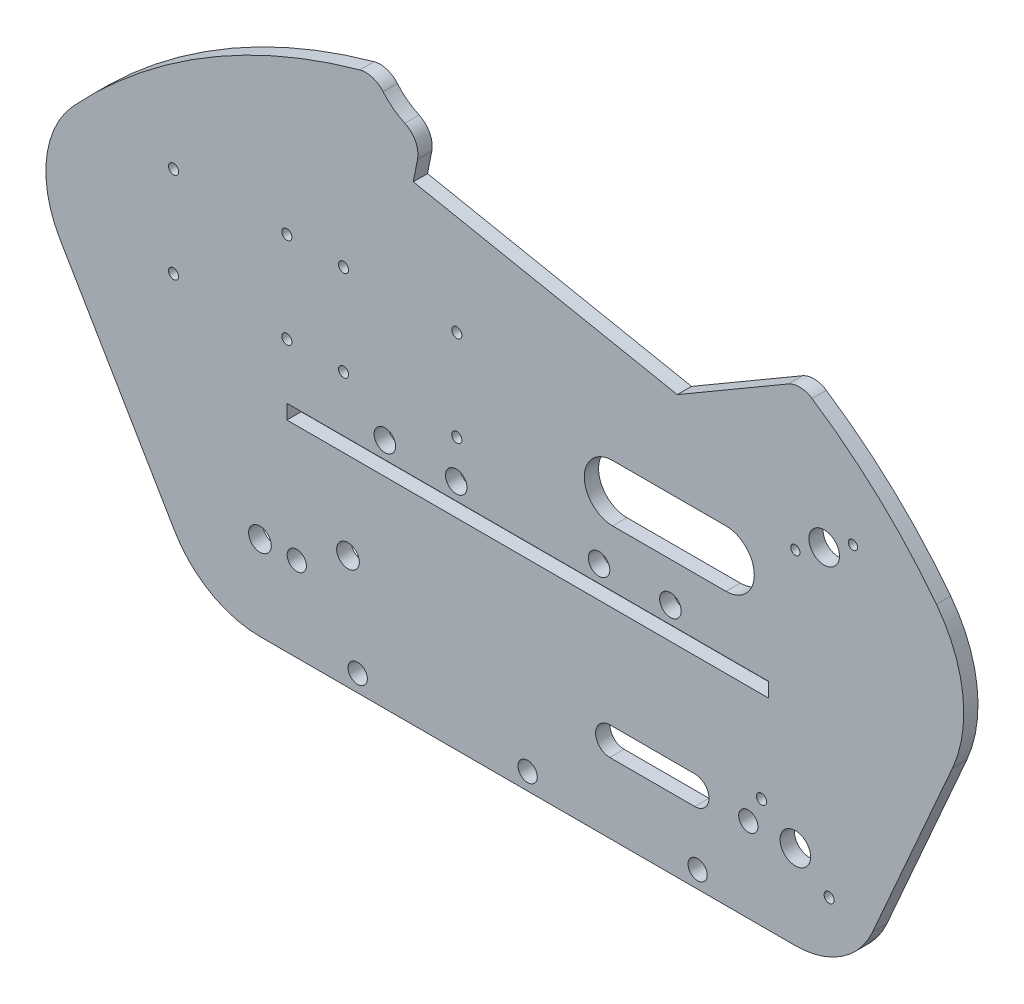
from build123d import *

# Parameters (mm, degrees)
SKETCH1_R           = 3.429
SKETCH1_R_2         = 2.54
BOSS_EXTRUDE1_DEPTH = 3.2004
SKETCH2_R           = 2.413
CUT_EXTRUDE1_DEPTH  = 3.2004
SKETCH3_R           = 2.159
CUT_EXTRUDE2_DEPTH  = 3.2004
SKETCH6_W           = 107.95
SKETCH6_H           = 3.2512
CUT_EXTRUDE3_DEPTH  = 3.2004
SKETCH7_R           = 3.429
CUT_EXTRUDE4_DEPTH  = 3.2004
CUT_EXTRUDE5_DEPTH  = 3.2004
CUT_EXTRUDE6_DEPTH  = 3.2004
BOSS_EXTRUDE2_DEPTH = 3.2004
SKETCH13_R          = 1.1303
CUT_EXTRUDE7_DEPTH  = 3.2004
CUT_EXTRUDE8_DEPTH  = 3.2004
FILLET1_R           = 5.08
SKETCH16_R          = 1.1303
SKETCH16_R_2        = 1.025
CUT_EXTRUDE9_DEPTH  = 3.2004
SKETCH20_R          = 2.159
CUT_EXTRUDE11_DEPTH = 3.2004


with BuildPart() as part:
    # Sketch1 → Boss-Extrude1 (new body)
    with BuildSketch(Plane.XY):
        with BuildLine():
            Line((0, 0), (120.015, 0))
            ThreePointArc((120.015, 0), (130.351788396, 3.075697789), (137.325636158, 11.302152592))
            Line((137.325636158, 11.302152592), (155.2575, 52.11572))
            ThreePointArc((155.2575, 52.11572), (157.54731739, 67.602183396), (151.630955452, 82.09599151))
            ThreePointArc((151.630955452, 82.09599151), (60.0075, 127.266502568), (-31.615955452, 82.09599151))
            ThreePointArc((-31.615955452, 82.09599151), (-37.53231739, 67.602183396), (-35.2425, 52.11572))
            Line((-35.2425, 52.11572), (-17.310636158, 11.302152592))
            ThreePointArc((-17.310636158, 11.302152592), (-10.336788396, 3.075697789), (0, 0))
        make_face()
        with Locations((120.015, 18.90776)):
            Circle(SKETCH1_R, mode=Mode.SUBTRACT)
        with Locations((0, 18.90776)):
            Circle(SKETCH1_R_2, mode=Mode.SUBTRACT)
        with Locations((19.734727626, 25.566426992)):
            Circle(SKETCH1_R_2, mode=Mode.SUBTRACT)
    extrude(amount=BOSS_EXTRUDE1_DEPTH)

    # Sketch2 → Cut-Extrude1 (cut)
    with BuildSketch(Plane(origin=(0, 0, 0), x_dir=(-1, 0, 0), z_dir=(0, 0, -1))):
        with Locations((-92.0115, 52.11572)):
            Circle(SKETCH2_R)
        with Locations((-76.0095, 52.11572)):
            Circle(SKETCH2_R)
        with Locations((-44.0055, 52.11572)):
            Circle(SKETCH2_R)
        with Locations((-28.0035, 52.11572)):
            Circle(SKETCH2_R)
    extrude(amount=-CUT_EXTRUDE1_DEPTH, mode=Mode.SUBTRACT)

    # Sketch3 → Cut-Extrude2 (cut)
    with BuildSketch(Plane.XY.offset(3.2004)):
        with Locations((21.9075, 3.81)):
            Circle(SKETCH3_R)
        with Locations((60.0075, 3.81)):
            Circle(SKETCH3_R)
        with Locations((98.1075, 3.81)):
            Circle(SKETCH3_R)
    extrude(amount=-CUT_EXTRUDE2_DEPTH, mode=Mode.SUBTRACT)

    # Sketch6 → Cut-Extrude3 (cut)
    with BuildSketch(Plane(origin=(0, 0, 0), x_dir=(-1, 0, 0), z_dir=(0, 0, -1))):
        with Locations((-60.0075, 46.68012)):
            Rectangle(SKETCH6_W, SKETCH6_H)
    extrude(amount=-CUT_EXTRUDE3_DEPTH, mode=Mode.SUBTRACT)

    # Sketch7 → Cut-Extrude4 (cut)
    with BuildSketch(Plane.XY.offset(3.2004)):
        with Locations((126.474462556, 80.535782848)):
            Circle(SKETCH7_R)
    extrude(amount=-CUT_EXTRUDE4_DEPTH, mode=Mode.SUBTRACT)

    # Sketch11 → Cut-Extrude5 (cut)
    with BuildSketch(Plane.XY.offset(3.2004)):
        with BuildLine():
            Line((121.0824837, 109.799267349), (93.538394554, 93.734155779))
            Line((93.538394554, 93.734155779), (34.363029741, 105.455155066))
            Line((34.363029741, 105.455155066), (38.27464621, 125.20358486))
            ThreePointArc((38.27464621, 125.20358486), (81.132699311, 125.318307405), (121.0824837, 109.799267349))
        make_face()
    extrude(amount=-CUT_EXTRUDE5_DEPTH, mode=Mode.SUBTRACT)

    # Sketch12 → Cut-Extrude6 (cut)
    with BuildSketch(Plane.XY.offset(3.2004)):
        with BuildLine():
            Line((35.641093634, 114.854322507), (36.202710537, 114.743081768))
            Line((36.202710537, 114.743081768), (38.27464621, 125.20358486))
            ThreePointArc((38.27464621, 125.20358486), (32.033357942, 123.827921759), (25.877709031, 122.109167938))
            ThreePointArc((25.877709031, 122.109167938), (29.941556488, 117.381110641), (35.641093634, 114.854322507))
        make_face()
    extrude(amount=-CUT_EXTRUDE6_DEPTH, mode=Mode.SUBTRACT)

    # Sketch14 → Boss-Extrude2 (add)
    with BuildSketch(Plane.XY.offset(3.2004)):
        with BuildLine():
            Line((-44.811597123, 54.685748683), (-19.142507527, 10.95973357))
            ThreePointArc((-19.142507527, 10.95973357), (-11.028954555, 2.933815076), (0, 0))
            ThreePointArc((0, 0), (-12.648210364, 66.477064779), (25.877709031, 122.109167938))
            ThreePointArc((25.877709031, 122.109167938), (-10.925402455, 107.037965152), (-41.85988351, 82.044605027))
            ThreePointArc((-41.85988351, 82.044605027), (-47.856144624, 68.852877757), (-44.811597123, 54.685748683))
        make_face()
    extrude(amount=-BOSS_EXTRUDE2_DEPTH)

    # Sketch13 → Cut-Extrude7 (cut)
    with BuildSketch(Plane.XY.offset(3.2004)):
        with Locations((44.1325, 81.07172)):
            Circle(SKETCH13_R)
        with Locations((44.1325, 60.75172)):
            Circle(SKETCH13_R)
        with Locations((18.7325, 60.75172)):
            Circle(SKETCH13_R)
        with Locations((18.7325, 81.07172)):
            Circle(SKETCH13_R)
        with Locations((6.0325, 81.07172)):
            Circle(SKETCH13_R)
        with Locations((6.0325, 60.75172)):
            Circle(SKETCH13_R)
        with Locations((-19.3675, 60.75172)):
            Circle(SKETCH13_R)
        with Locations((-19.3675, 81.07172)):
            Circle(SKETCH13_R)
    extrude(amount=-CUT_EXTRUDE7_DEPTH, mode=Mode.SUBTRACT)

    # Sketch15 → Cut-Extrude8 (cut)
    with BuildSketch(Plane.XY.offset(3.2004)):
        with BuildLine():
            Line((79.0575, 73.70572), (104.4575, 73.70572))
            ThreePointArc((104.4575, 73.70572), (110.8075, 67.35572), (104.4575, 61.00572))
            Line((104.4575, 61.00572), (79.0575, 61.00572))
            ThreePointArc((79.0575, 61.00572), (72.7075, 67.35572), (79.0575, 73.70572))
        make_face()
        with BuildLine():
            Line((78.4225, 22.08276), (97.4725, 22.08276))
            ThreePointArc((97.4725, 22.08276), (100.6475, 18.90776), (97.4725, 15.73276))
            Line((97.4725, 15.73276), (78.4225, 15.73276))
            ThreePointArc((78.4225, 15.73276), (75.2475, 18.90776), (78.4225, 22.08276))
        make_face()
    extrude(amount=-CUT_EXTRUDE8_DEPTH, mode=Mode.SUBTRACT)

    # Fillet1
    fillet1_edges = [part.edges().sort_by_distance(p)[0] for p in [
        (121.0824837, 109.799267349, 1.6002),
        (36.202710537, 114.743081768, 1.6002),
        (25.877709031, 122.109167938, 1.6002),
    ]]
    fillet(fillet1_edges, radius=FILLET1_R)

    # Sketch16 → Cut-Extrude9 (cut)
    with BuildSketch(Plane.XY.offset(3.2004)):
        with Locations((112.438115095, 24.679799513)):
            Circle(SKETCH16_R)
        with Locations((127.591884905, 13.135720487)):
            Circle(SKETCH16_R)
        with Locations((120.029328249, 76.814682821)):
            Circle(SKETCH16_R_2)
        with Locations((132.919596863, 84.256882875)):
            Circle(SKETCH16_R_2)
    extrude(amount=-CUT_EXTRUDE9_DEPTH, mode=Mode.SUBTRACT)

    # Sketch20 → Cut-Extrude11 (cut)
    with BuildSketch(Plane.XY.offset(3.2004)):
        with Locations((8.255, 18.90776)):
            Circle(SKETCH20_R)
        with Locations((109.47654, 18.90776)):
            Circle(SKETCH20_R)
    extrude(amount=-CUT_EXTRUDE11_DEPTH, mode=Mode.SUBTRACT)


solid = part.part
